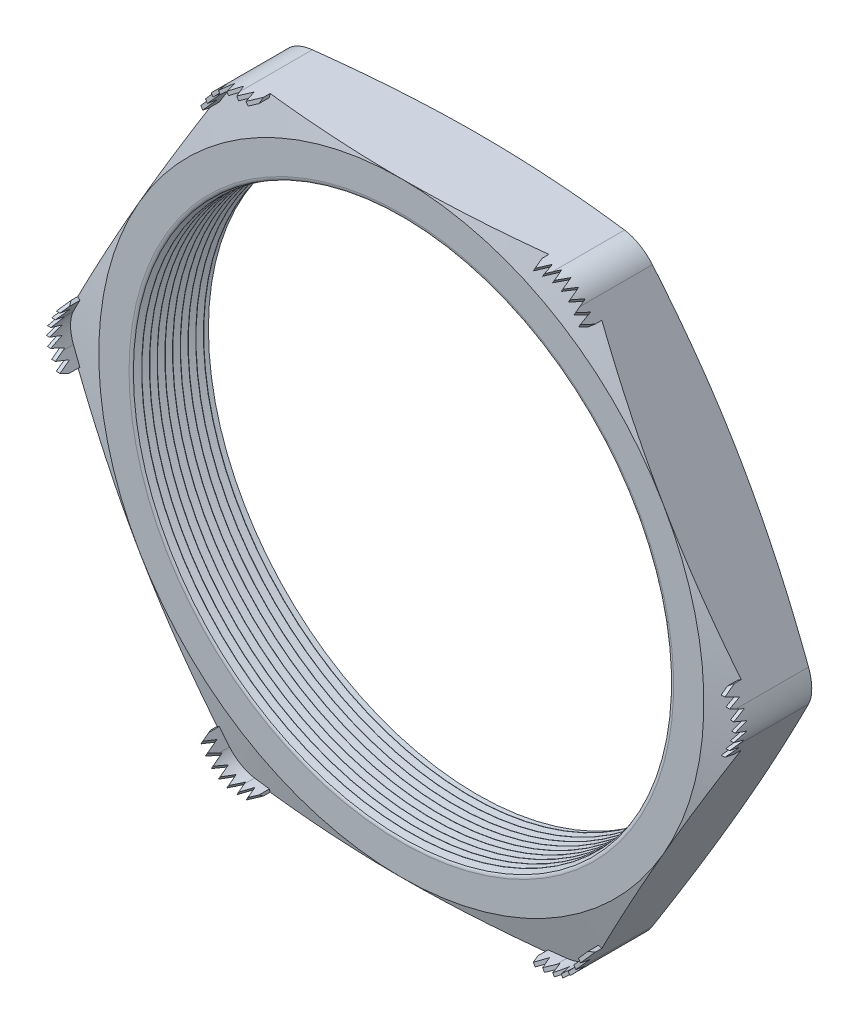
from build123d import *

# Parameters (mm, degrees)
SKETCH1_R          = 10.541
EXTRUDE1_DEPTH     = 3.048
FILLET1_R          = 1.27
FILLET3_R          = 0.2032
LPATTERN1_COUNT    = 10
LPATTERN1_PITCH    = 0.3048
SKETCH4_OUTSIDE_W  = 66.652
SKETCH4_OUTSIDE_H  = 63.352
SKETCH4_OUTSIDE_R  = 11.938
CUT_EXTRUDE1_DEPTH = 4.048
CUT_EXTRUDE1_DRAFT = -75
SKETCH5_OUTSIDE_W  = 66.652
SKETCH5_OUTSIDE_H  = 63.352
SKETCH5_OUTSIDE_R  = 11.938
CUT_EXTRUDE2_DEPTH = 4.0480001
CUT_EXTRUDE2_DRAFT = -75
EXTRUDE2_START     = -0.442209
EXTRUDE2_DEPTH     = 1.585209
CUT_EXTRUDE4_DEPTH = 5.154771699
CIRPATTERN1_COUNT  = 6
CIRPATTERN2_COUNT  = 6


with BuildPart() as part:
    # Sketch1 → Extrude1 (new body)
    with BuildSketch(Plane.XY):
        Polygon((-13.784815027, 0), (-6.892407514, -11.938), (6.892407514, -11.938), (13.784815027, 0), (6.892407514, 11.938), (-6.892407514, 11.938), align=None)
        Circle(SKETCH1_R, mode=Mode.SUBTRACT)
    extrude(amount=EXTRUDE1_DEPTH)

    # Fillet1
    fillet1_edges = [part.edges().sort_by_distance(p)[0] for p in [
        (13.784815027, 0, 1.524),
        (6.892407514, -11.938, 1.524),
        (-6.892407514, -11.938, 1.524),
        (-13.784815027, 0, 1.524),
        (-6.892407514, 11.938, 1.524),
        (6.892407514, 11.938, 1.524),
    ]]
    fillet(fillet1_edges, radius=FILLET1_R)

    # Fillet3
    fillet3_edges = [part.edges().sort_by_distance(p)[0] for p in [
        (-10.541, 0, 0),
        (-10.541, 0, 3.048),
    ]]
    fillet(fillet3_edges, radius=FILLET3_R)

    # Sketch3 → Cut-Revolve1 (revolve, cut)
    with BuildSketch(Plane(origin=(0, 0, 0), x_dir=(1, 0, 0), z_dir=(0, 1, 0))):
        Polygon((-10.541, -3.048), (-10.541, -2.754706063), (-10.795, -2.901353032), align=None)
    cut_revolve1 = revolve(axis=Axis((0, 0, 3.048), (0, 0, -1)), mode=Mode.SUBTRACT)

    # LPattern1: Cut-Revolve1 ×10
    with Locations(*[(0, 0, -i * LPATTERN1_PITCH) for i in range(1, LPATTERN1_COUNT)]):
        add(cut_revolve1, mode=Mode.SUBTRACT)


with BuildPart() as cut_extrude1_tool:
    # Sketch4 outside → Cut-Extrude1 (with draft: the straight prism first)
    with BuildSketch(Plane(origin=(0, 0, 0), x_dir=(-1, 0, 0), z_dir=(0, 0, -1))):
        Rectangle(SKETCH4_OUTSIDE_W, SKETCH4_OUTSIDE_H)
        Circle(SKETCH4_OUTSIDE_R, mode=Mode.SUBTRACT)
    extrude(amount=-CUT_EXTRUDE1_DEPTH)
    # Cut-Extrude1: the draft: its side faces are tilted about the plane it starts from
    cut_extrude1_sides = [cut_extrude1_tool.faces().sort_by_distance(p)[0] for p in [
        (0, -31.676, 2.024),
        (-33.326, 0, 2.024),
        (0, 31.676, 2.024),
        (33.326, 0, 2.024),
        (11.938, 0, 2.024),
    ]]
    draft(cut_extrude1_sides, Plane(origin=(0, 0, 0), x_dir=(-1, 0, 0), z_dir=(0, 0, -1)), CUT_EXTRUDE1_DRAFT)


with BuildPart() as part_1:
    add(part.part)

    # Cut-Extrude1: cut by cut_extrude1_tool
    add(cut_extrude1_tool.part, mode=Mode.SUBTRACT)


with BuildPart() as cut_extrude2_tool:
    # Sketch5 outside → Cut-Extrude2 (with draft: the straight prism first)
    with BuildSketch(Plane.XY.offset(3.048)):
        Rectangle(SKETCH5_OUTSIDE_W, SKETCH5_OUTSIDE_H)
        Circle(SKETCH5_OUTSIDE_R, mode=Mode.SUBTRACT)
    extrude(amount=-CUT_EXTRUDE2_DEPTH)
    # Cut-Extrude2: the draft: its side faces are tilted about the plane it starts from
    cut_extrude2_sides = [cut_extrude2_tool.faces().sort_by_distance(p)[0] for p in [
        (0, -31.676, 1.02399995),
        (33.326, 0, 1.02399995),
        (0, 31.676, 1.02399995),
        (-33.326, 0, 1.02399995),
        (-11.938, 0, 1.02399995),
    ]]
    draft(cut_extrude2_sides, Plane.XY.offset(3.048), CUT_EXTRUDE2_DRAFT)


with BuildPart() as part_2:
    add(part_1.part)

    # Cut-Extrude2: cut by cut_extrude2_tool
    add(cut_extrude2_tool.part, mode=Mode.SUBTRACT)

    # Sketch2 → Extrude2 (add)
    with BuildSketch(Plane.XY.offset(3.048).offset(EXTRUDE2_START)):
        with BuildLine():
            Line((-6.159172672, 11.938), (-5.498772672, 11.938))
            Line((-5.498772672, 11.938), (-5.498772672, 11.811))
            Line((-5.498772672, 11.811), (-6.159172672, 11.811))
            ThreePointArc((-6.159172672, 11.811), (-6.730672672, 11.657867037), (-7.149039708, 11.2395))
            Line((-7.149039708, 11.2395), (-7.479239708, 10.667576823))
            Line((-7.479239708, 10.667576823), (-7.589224935, 10.731076823))
            Line((-7.589224935, 10.731076823), (-7.259024935, 11.303))
            ThreePointArc((-7.259024935, 11.303), (-6.794172672, 11.767852263), (-6.159172672, 11.938))
        make_face()
    extrude2 = extrude(amount=EXTRUDE2_DEPTH)

    # Sketch7 → Cut-Extrude4 (cut, through all)
    with BuildSketch(Plane(origin=(-6.48900619, 11.239288412, 0), x_dir=(0.866025404, 0.5, 0), z_dir=(0.5, -0.866025404, 0))):
        Polygon((-1.206923177, 2.99085), (-1.029123177, 3.47091), (-0.851323177, 2.99085), (-0.7112, 3.47091), (-0.5334, 2.99085), (-0.3556, 3.47091), (-0.1778, 2.99085), (0, 3.47091), (0.1778, 2.99085), (0.3556, 3.47091), (0.5334, 2.99085), (0.7112, 3.47091), (0.889, 2.99085), (1.029123177, 3.47091), (1.206923177, 2.99085), (1.206923177, 4.191), (-1.206923177, 4.191), align=None)
    cut_extrude4 = extrude(amount=-CUT_EXTRUDE4_DEPTH, mode=Mode.SUBTRACT)

    # CirPattern1: Extrude2 ×6 about axis
    cirpattern1_axis = Axis((0, 0, 0), (0, 0, 1))
    for i in range(1, CIRPATTERN1_COUNT):
        add(extrude2.rotate(cirpattern1_axis, i * 360 / CIRPATTERN1_COUNT))

    # CirPattern2: Cut-Extrude4 ×6 about axis
    cirpattern2_axis = Axis((0, 0, 0), (0, 0, 1))
    for i in range(1, CIRPATTERN2_COUNT):
        add(cut_extrude4.rotate(cirpattern2_axis, i * 360 / CIRPATTERN2_COUNT), mode=Mode.SUBTRACT)


solid = part_2.part
